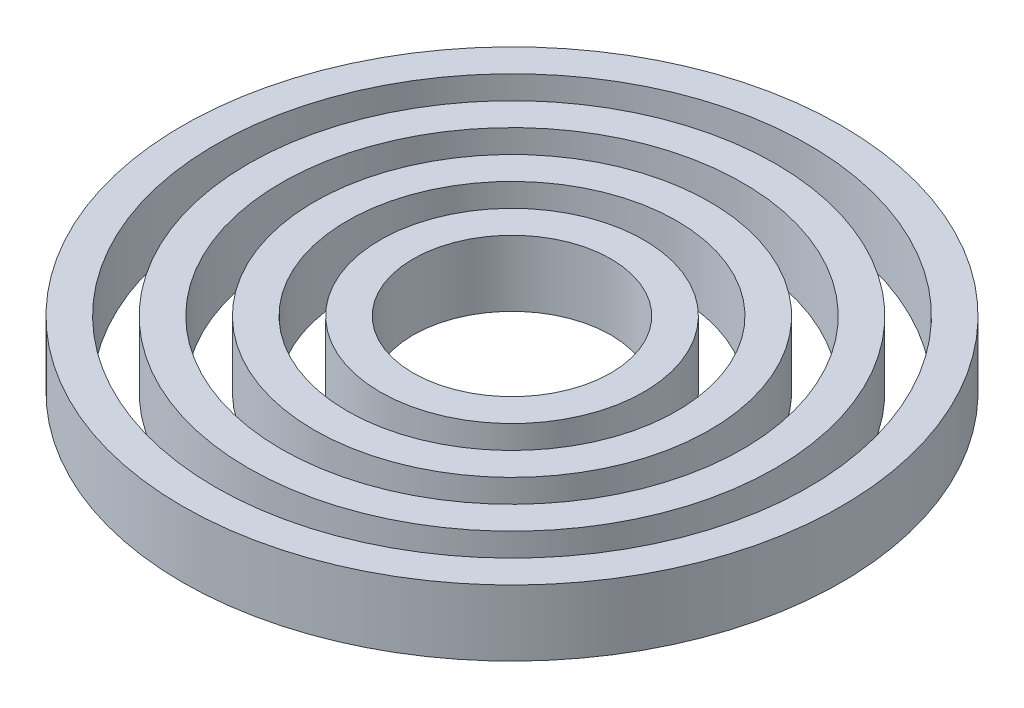
from build123d import *

# Parameters (mm, degrees)
SKETCH1_R             = 50
SKETCH1_R_2           = 45
BOSS_EXTRUDE3_DEPTH   = 10
SKETCH1_R_3           = 40
SKETCH1_R_4           = 35
BOSS_EXTRUDE3_2_DEPTH = 10
SKETCH1_R_5           = 30
SKETCH1_R_6           = 25
BOSS_EXTRUDE3_3_DEPTH = 10
SKETCH1_R_7           = 20
SKETCH1_R_8           = 15
BOSS_EXTRUDE3_4_DEPTH = 10


with BuildPart() as part:
    # Sketch1 → Boss-Extrude3 (new body)
    with BuildSketch(Plane(origin=(0, 0, 0), x_dir=(1, 0, 0), z_dir=(0, 1, 0))):
        with Locations((11.359496118, -7.347893769)):
            Circle(SKETCH1_R)
        with Locations((11.359496118, -7.347893769)):
            Circle(SKETCH1_R_2, mode=Mode.SUBTRACT)
    extrude(amount=BOSS_EXTRUDE3_DEPTH)


with BuildPart() as body_2:
    # Sketch1 → Boss-Extrude3 2 (new body)
    with BuildSketch(Plane(origin=(0, 0, 0), x_dir=(1, 0, 0), z_dir=(0, 1, 0))):
        with Locations((11.359496118, -7.347893769)):
            Circle(SKETCH1_R_3)
        with Locations((11.359496118, -7.347893769)):
            Circle(SKETCH1_R_4, mode=Mode.SUBTRACT)
    extrude(amount=BOSS_EXTRUDE3_2_DEPTH)


with BuildPart() as body_3:
    # Sketch1 → Boss-Extrude3 3 (new body)
    with BuildSketch(Plane(origin=(0, 0, 0), x_dir=(1, 0, 0), z_dir=(0, 1, 0))):
        with Locations((11.359496118, -7.347893769)):
            Circle(SKETCH1_R_5)
        with Locations((11.359496118, -7.347893769)):
            Circle(SKETCH1_R_6, mode=Mode.SUBTRACT)
    extrude(amount=BOSS_EXTRUDE3_3_DEPTH)


with BuildPart() as body_4:
    # Sketch1 → Boss-Extrude3 4 (new body)
    with BuildSketch(Plane(origin=(0, 0, 0), x_dir=(1, 0, 0), z_dir=(0, 1, 0))):
        with Locations((11.359496118, -7.347893769)):
            Circle(SKETCH1_R_7)
        with Locations((11.359496118, -7.347893769)):
            Circle(SKETCH1_R_8, mode=Mode.SUBTRACT)
    extrude(amount=BOSS_EXTRUDE3_4_DEPTH)


solid = Compound([part.part, body_2.part, body_3.part, body_4.part])
